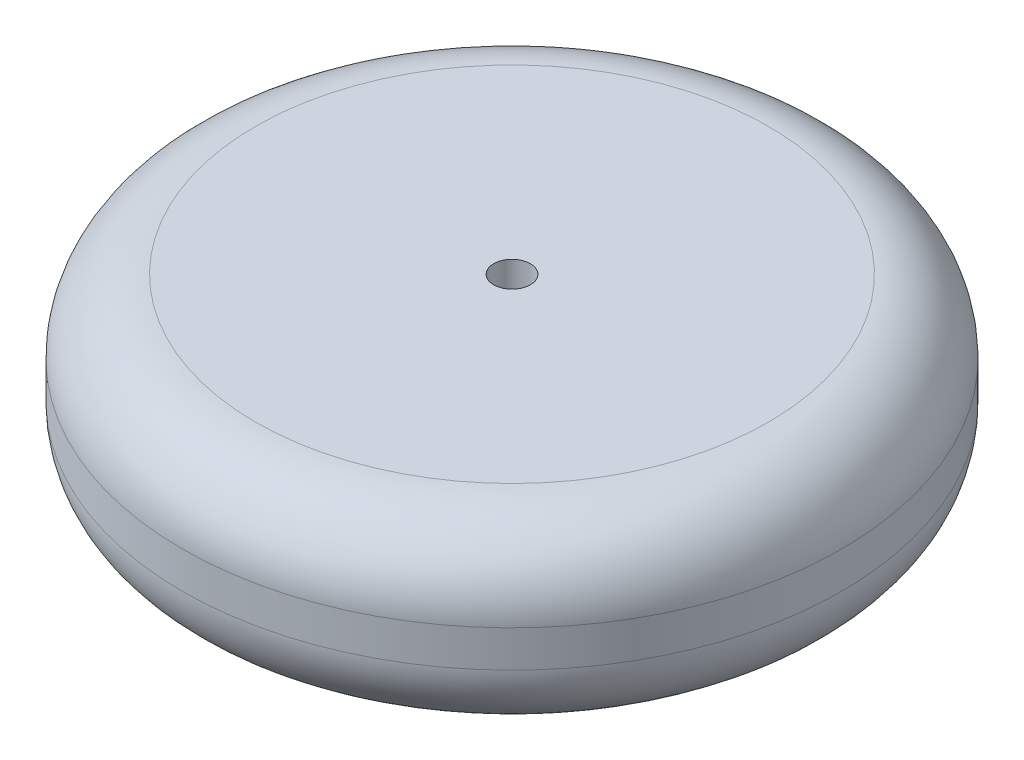
from build123d import *

# Parameters (mm, degrees)
BOSS_EXTRUDE1_DEPTH      = 31.75
BOSS_EXTRUDE1_DEPTH_BACK = 31.75
SKETCH1_R                = 114.3
FILLET1_R                = 25.4
SKETCH2_R                = 6.35
CUT_EXTRUDE1_DEPTH       = 107.188


with BuildPart() as part:
    # Sketch1 → Boss-Extrude1 (new, two sides: drawn at the far end of the back side and taken through both)
    with BuildSketch(Plane(origin=(0, 0, 0), x_dir=(1, 0, 0), z_dir=(0, 1, 0)).offset(-BOSS_EXTRUDE1_DEPTH_BACK)):
        Circle(SKETCH1_R)
    extrude(amount=BOSS_EXTRUDE1_DEPTH + BOSS_EXTRUDE1_DEPTH_BACK)

    # Fillet1
    fillet1_edges = [part.edges().sort_by_distance(p)[0] for p in [
        (-114.3, -31.75, 0),
        (-114.3, 31.75, 0),
    ]]
    fillet(fillet1_edges, radius=FILLET1_R)

    # Sketch2 → Cut-Extrude1 (cut)
    with BuildSketch(Plane(origin=(0, 31.75, 0), x_dir=(1, 0, 0), z_dir=(0, 1, 0))):
        Circle(SKETCH2_R)
    extrude(amount=-CUT_EXTRUDE1_DEPTH, mode=Mode.SUBTRACT)


solid = part.part
